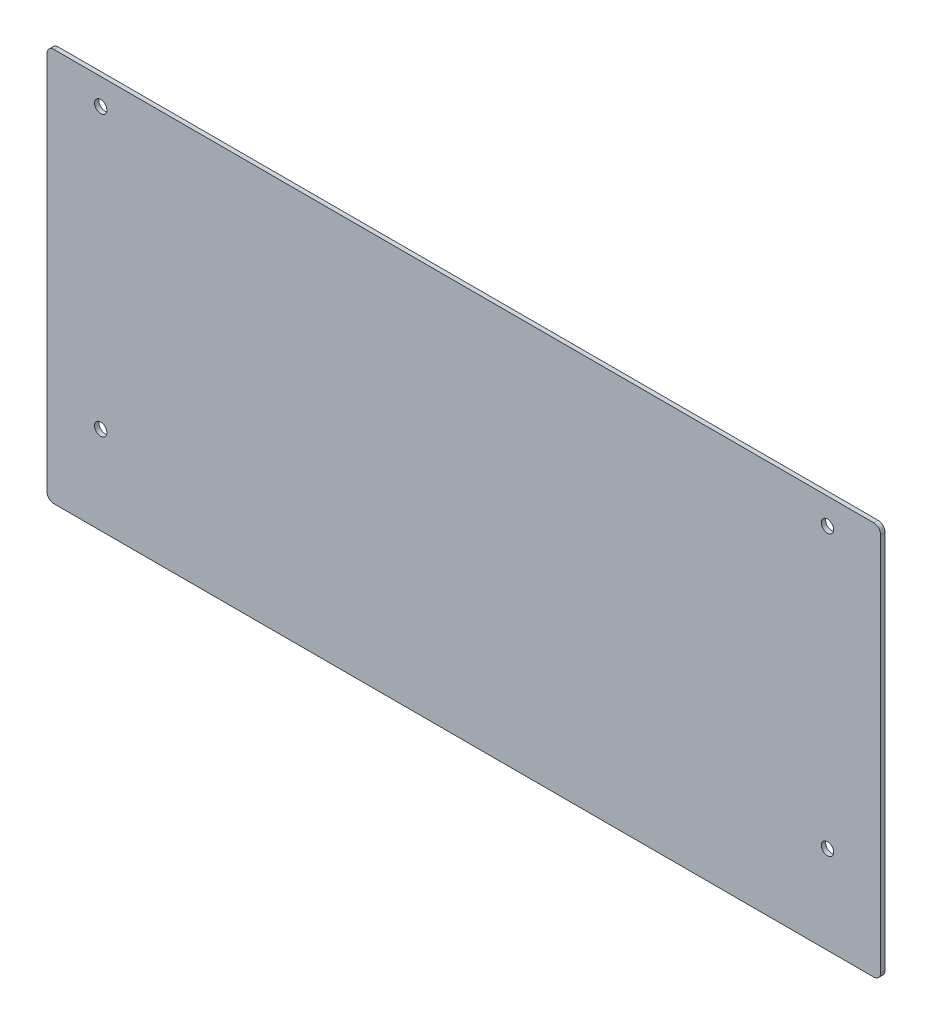
from build123d import *

# Parameters (mm, degrees)
SKETCH1_W            = 304.478126018
SKETCH1_H            = 143.693200147
SKETCH1_R            = 1.963769259
SKETCH1_R_2          = 1.779821827
SKETCH1_R_3          = 1.61224473
SKETCH1_R_4          = 1.682415614
BOSS_EXTRUDE1_DEPTH  = 1.5875
FILLET1_R            = 2.54
M4_CLEARANCE_HOLE1_D = 4.5


with BuildPart() as part:
    # Sketch1 → Boss-Extrude1 (new body)
    with BuildSketch(Plane.XY):
        with Locations((162.727004442, -233.274517622)):
            Rectangle(SKETCH1_W, SKETCH1_H)
        with Locations((30.106067449, -170.952944133)):
            Circle(SKETCH1_R, mode=Mode.SUBTRACT)
        with Locations((295.536067449, -170.952944133)):
            Circle(SKETCH1_R_2, mode=Mode.SUBTRACT)
        with Locations((295.536067449, -272.978890964)):
            Circle(SKETCH1_R_3, mode=Mode.SUBTRACT)
        with Locations((30.106067449, -272.978890964)):
            Circle(SKETCH1_R_4, mode=Mode.SUBTRACT)
    extrude(amount=BOSS_EXTRUDE1_DEPTH)

    # Fillet1
    fillet1_edges = [part.edges().sort_by_distance(p)[0] for p in [
        (10.487941433, -161.427917548, 0.79375),
        (314.966067451, -161.427917548, 0.79375),
        (314.966067451, -305.121117695, 0.79375),
        (10.487941433, -305.121117695, 0.79375),
    ]]
    fillet(fillet1_edges, radius=FILLET1_R)

    # M4 Clearance Hole1 (through all)
    with Locations(Plane.XY.offset(1.5875)):
        with Locations((30.106067449, -170.952944133), (30.106067449, -272.978890964), (295.536067449, -170.952944133), (295.536067449, -272.978890964)):
            Hole(M4_CLEARANCE_HOLE1_D / 2)


solid = part.part
